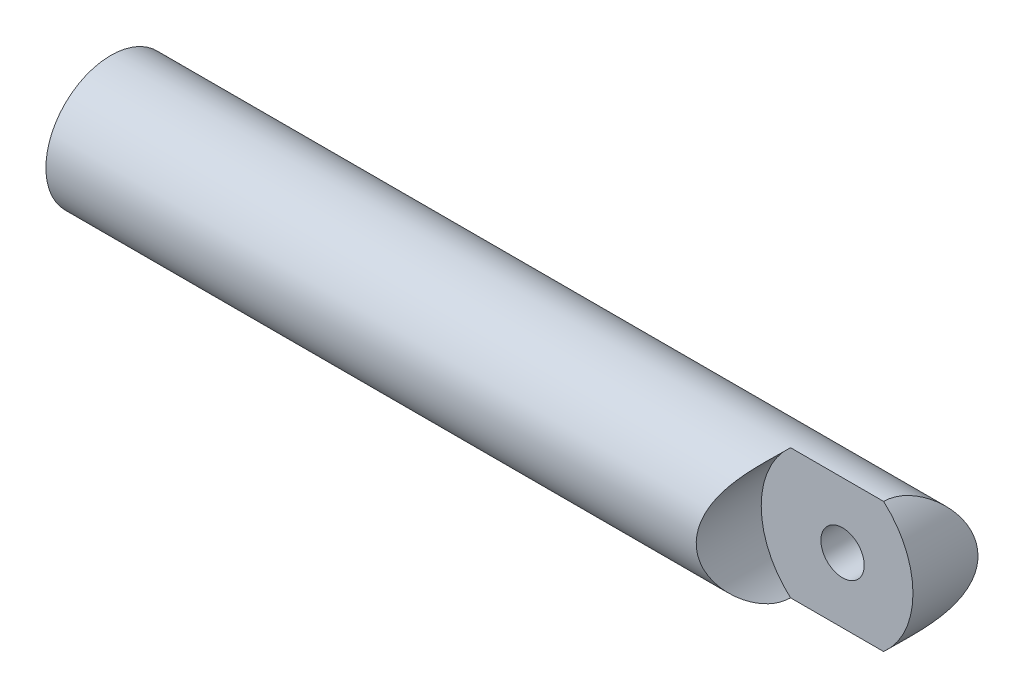
from build123d import *

# Parameters (mm, degrees)
SKETCH1_R               = 4.70408
BOSS_EXTRUDE1_DEPTH     = 58.02376
CUT_EXTRUDE1_DEPTH      = 5.70408
CUT_EXTRUDE1_DEPTH_BACK = 5.70408
SKETCH3_R               = 6.2738
CUT_EXTRUDE2_DEPTH      = 5.704080123
SKETCH4_R               = 1.56718
CUT_EXTRUDE3_DEPTH      = 5.7040801


with BuildPart() as part:
    # Sketch1 → Boss-Extrude1 (new body)
    with BuildSketch(Plane(origin=(0, 0, 0), x_dir=(0, 0, -1), z_dir=(1, 0, 0))):
        Circle(SKETCH1_R)
    extrude(amount=-BOSS_EXTRUDE1_DEPTH)

    # Sketch2 → Cut-Extrude1 (cut, two sides)
    with BuildSketch(Plane.XY) as cut_extrude1_sk:
        with BuildLine():
            Line((-6.2738, 6.2738), (2.931020603, 6.2738))
            Line((2.931020603, 6.2738), (2.931020603, -6.2738))
            Line((2.931020603, -6.2738), (-6.2738, -6.2738))
            ThreePointArc((-6.2738, -6.2738), (0, 0), (-6.2738, 6.2738))
        make_face()
    extrude(amount=CUT_EXTRUDE1_DEPTH, mode=Mode.SUBTRACT)
    extrude(cut_extrude1_sk.sketch, amount=-CUT_EXTRUDE1_DEPTH_BACK, mode=Mode.SUBTRACT)

    # Sketch3 → Cut-Extrude2 (cut, through all)
    with BuildSketch(Plane.XY):
        with Locations((-4.70408, 0)):
            Circle(SKETCH3_R)
    extrude(amount=CUT_EXTRUDE2_DEPTH, mode=Mode.SUBTRACT)

    # Sketch4 → Cut-Extrude3 (cut, through all)
    with BuildSketch(Plane.XY):
        with Locations((-5.09524, 0)):
            Circle(SKETCH4_R)
    extrude(amount=-CUT_EXTRUDE3_DEPTH, mode=Mode.SUBTRACT)


solid = part.part
